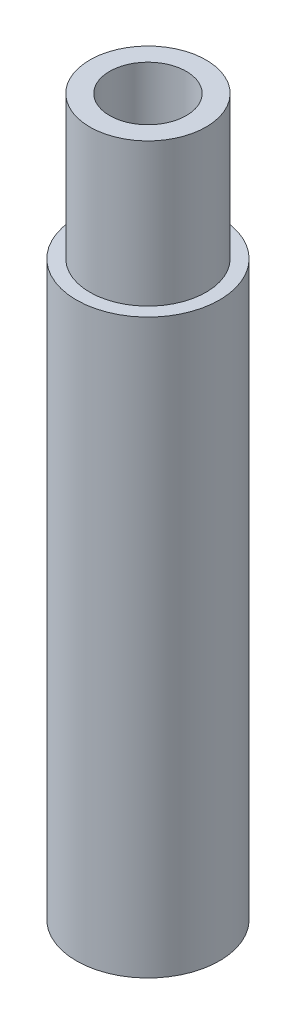
from build123d import *

# Parameters (mm, degrees)
SKETCH1_R          = 3.175
SKETCH1_R_2        = 1.7018
EXTRUDE1_DEPTH     = 31.75
SKETCH2_R          = 3.175
SKETCH2_R_2        = 2.5796875
CUT_EXTRUDE1_DEPTH = 6.35


with BuildPart() as part:
    # Sketch1 → Extrude1 (new body)
    with BuildSketch(Plane(origin=(0, 0, 0), x_dir=(1, 0, 0), z_dir=(0, 1, 0))):
        Circle(SKETCH1_R)
        Circle(SKETCH1_R_2, mode=Mode.SUBTRACT)
    extrude(amount=EXTRUDE1_DEPTH)

    # Sketch2 → Cut-Extrude1 (cut)
    with BuildSketch(Plane(origin=(0, 31.75, 0), x_dir=(-1, 0, 0), z_dir=(0, 1, 0))):
        Circle(SKETCH2_R)
        Circle(SKETCH2_R_2, mode=Mode.SUBTRACT)
    extrude(amount=-CUT_EXTRUDE1_DEPTH, mode=Mode.SUBTRACT)


solid = part.part
